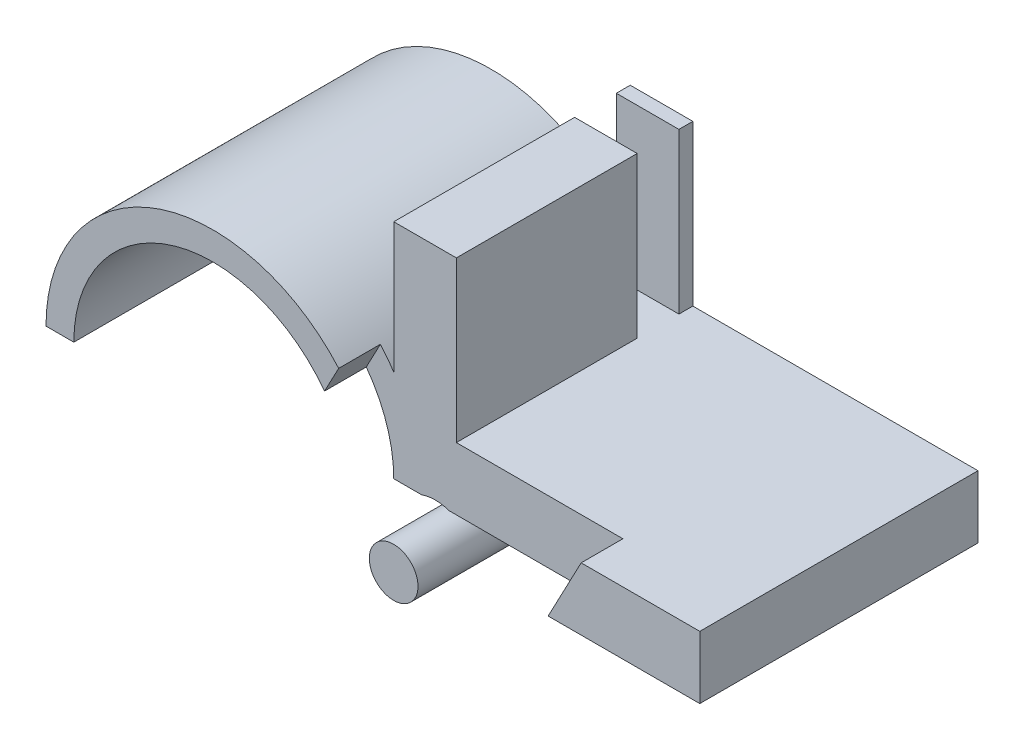
from build123d import *

# Parameters (mm, degrees)
BOSS_EXTRUDE1_DEPTH = 20
SKETCH7_R           = 1.75
BOSS_EXTRUDE5_DEPTH = 20
BOSS_EXTRUDE6_DEPTH = 5
SKETCH8_W           = 25
SKETCH8_H           = 20
BOSS_EXTRUDE7_DEPTH = 4.5
SKETCH9_W           = 4.5
SKETCH9_H           = 20
BOSS_EXTRUDE8_DEPTH = 16
SKETCH10_R          = 1.75
CUT_EXTRUDE1_DEPTH  = 3
SKETCH12_R          = 1.75
BOSS_EXTRUDE9_DEPTH = 3
SKETCH14_R          = 3
SKETCH14_R_2        = 2.333892431
CUT_EXTRUDE3_DEPTH  = 16
CUT_EXTRUDE4_DEPTH  = 3
SKETCH16_W          = 3
SKETCH16_H          = 11.5
CUT_EXTRUDE5_DEPTH  = 5


with BuildPart() as part:
    # Sketch1 → Boss-Extrude1 (new body)
    with BuildSketch(Plane.XY):
        with BuildLine():
            Line((-12, 0), (-10, 0))
            ThreePointArc((-10, 0), (0, 10), (10, 0))
            Line((10, 0), (12, 0))
            ThreePointArc((12, 0), (11.984990613, 0.6), (11.94, 1.198499061))
            ThreePointArc((11.94, 1.198499061), (11.893303563, 1.596662255), (11.833333333, 1.993043457))
            ThreePointArc((11.833333333, 1.993043457), (-1, 11.958260743), (-12, 0))
        make_face()
    extrude(amount=BOSS_EXTRUDE1_DEPTH)



with BuildPart() as body_2:
    # Sketch7 → Boss-Extrude5 (new body)
    with BuildSketch(Plane(origin=(0, 0, 0), x_dir=(-1, 0, 0), z_dir=(0, 0, -1))):
        with Locations((-12.991756156, -2.831328262)):
            Circle(SKETCH7_R)
    extrude(amount=-BOSS_EXTRUDE5_DEPTH)

    # Sketch5 → Boss-Extrude6 (add)
    with BuildSketch(Plane(origin=(0, 0, 0), x_dir=(-1, 0, 0), z_dir=(0, 0, -1))):
        with BuildLine():
            Line((-10, 0), (-10, -2.609078175))
            ThreePointArc((-10, -2.609078175), (-15.372704459, -4.656454335), (-12, 0))
            Line((-12, 0), (-10, 0))
        make_face()
    extrude(amount=-BOSS_EXTRUDE6_DEPTH)


with BuildPart() as part_1:
    add(part.part)

    add(body_2.part)  # Boss-Extrude7 merges body 2
    # Sketch8 → Boss-Extrude7 (add)
    with BuildSketch(Plane(origin=(0, 0, 0), x_dir=(1, 0, 0), z_dir=(0, 1, 0))):
        with Locations((22.5, -10)):
            Rectangle(SKETCH8_W, SKETCH8_H)
    extrude(amount=BOSS_EXTRUDE7_DEPTH)

    # Sketch9 → Boss-Extrude8 (add)
    with BuildSketch(Plane.XZ):
        with Locations((12.25, 10)):
            Rectangle(SKETCH9_W, SKETCH9_H)
    extrude(amount=-BOSS_EXTRUDE8_DEPTH)

    # Sketch10 → Cut-Extrude1 (cut)
    with BuildSketch(Plane.XY.offset(20)):
        with BuildLine():
            Line((10, 0), (24.09729333, 0))
            Line((24.09729333, 0), (26.472308955, 4.5))
            Line((26.472308955, 4.5), (14.5, 4.5))
            Line((14.5, 4.5), (14.5, 16))
            Line((14.5, 16), (14.022774425, 16))
            ThreePointArc((14.022774425, 16), (12.880514361, 14.832204973), (11.982740375, 13.467468681))
            Line((11.982740375, 13.467468681), (10, 9.710722159))
            Line((10, 9.710722159), (10, 6.633249581))
            ThreePointArc((10, 6.633249581), (9.540752339, 7.278327061), (9.039960442, 7.891711805))
            Line((9.039960442, 7.891711805), (8.02434549, 5.967401399))
            ThreePointArc((8.02434549, 5.967401399), (9.493246413, 3.142971929), (10, 0))
        make_face()
        with Locations(Location((12.991756156, -2.831328262, 0), (0, 0, 180))):
            Circle(SKETCH10_R)
    extrude(amount=-CUT_EXTRUDE1_DEPTH, mode=Mode.SUBTRACT)

    # Sketch12 → Boss-Extrude9 (add)
    with BuildSketch(Plane.XY.offset(17)):
        with Locations(Location((12.991756156, -2.831328262, 0), (0, 0, 180))):
            Circle(SKETCH12_R)
    extrude(amount=BOSS_EXTRUDE9_DEPTH)

    # Sketch14 → Cut-Extrude3 (cut)
    with BuildSketch(Plane.XY.offset(5)):
        with Locations((12.991756156, -2.831328262)):
            Circle(SKETCH14_R)
        with Locations((12.991756156, -2.831328262)):
            Circle(SKETCH14_R_2, mode=Mode.SUBTRACT)
    extrude(amount=CUT_EXTRUDE3_DEPTH, mode=Mode.SUBTRACT)

    # Sketch15 → Cut-Extrude4 (cut)
    with BuildSketch(Plane.XY.offset(20)):
        Polygon((9.332134569, 17.011722294), (15.835730862, 16.761583975), (11.722345172, 9.285227553), (9.050959886, 9.701180523), align=None)
    extrude(amount=-CUT_EXTRUDE4_DEPTH, mode=Mode.SUBTRACT)

    # Sketch16 → Cut-Extrude5 (cut)
    with BuildSketch(Plane(origin=(14.5, 0, 0), x_dir=(0, 0, -1), z_dir=(1, 0, 0))):
        with Locations((-2.5, 10.25)):
            Rectangle(SKETCH16_W, SKETCH16_H)
    extrude(amount=-CUT_EXTRUDE5_DEPTH, mode=Mode.SUBTRACT)


solid = part_1.part
